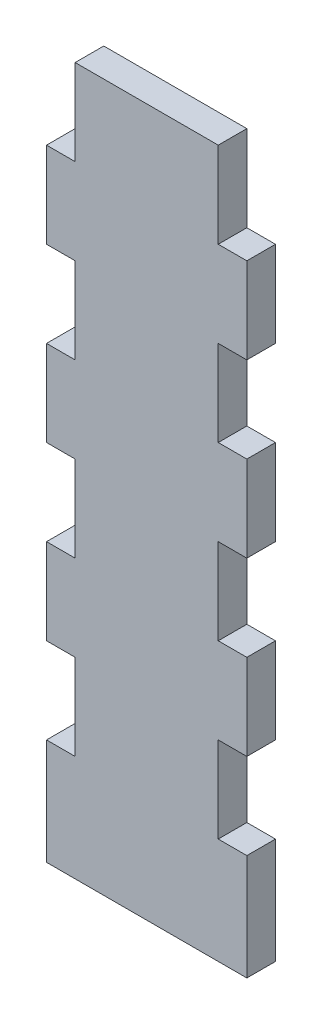
from build123d import *

# Parameters (mm, degrees)
BOSS_EXTRUDE1_DEPTH = 6


with BuildPart() as part:
    # Model → Boss-Extrude1 (new body)
    with BuildSketch(Plane.XY):
        Polygon((60.009337191, 137.701021173), (54.009337191, 137.701021173), (54.009337191, 155.701021173), (24.009337191, 155.701021173), (24.009337191, 137.701021173), (18.009337191, 137.701021173), (18.009337191, 119.701021173), (24.009337191, 119.701021173), (24.009337191, 101.701021173), (18.009337191, 101.701021173), (18.009337191, 83.701021173), (24.009337191, 83.701021173), (24.009337191, 65.701021173), (18.009337191, 65.701021173), (18.009337191, 47.701021173), (24.009337191, 47.701021173), (24.009337191, 29.701021173), (18.009337191, 29.701021173), (18.009337191, 11.701021173), (18.009337191, 7.470166535), (60.009337191, 7.470166535), (60.009337191, 11.701021173), (60.009337191, 29.701021173), (54.009337191, 29.701021173), (54.009337191, 47.701021173), (60.009337191, 47.701021173), (60.009337191, 65.701021173), (54.009337191, 65.701021173), (54.009337191, 83.701021173), (60.009337191, 83.701021173), (60.009337191, 101.701021173), (54.009337191, 101.701021173), (54.009337191, 119.701021173), (60.009337191, 119.701021173), align=None)
    extrude(amount=BOSS_EXTRUDE1_DEPTH)


solid = part.part
